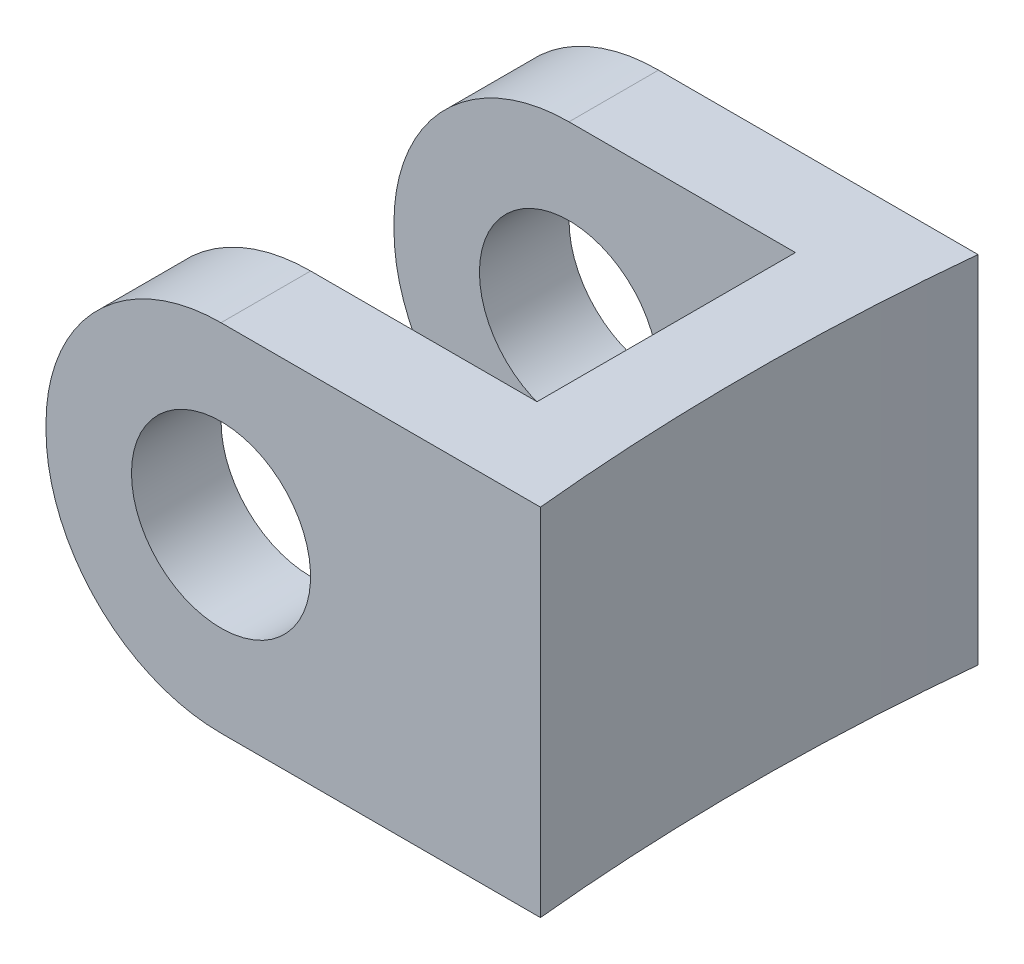
from build123d import *

# Parameters (mm, degrees)
BOSS_EXTRUDE2_DEPTH = 8.255
FILLET1_R           = 4.064
SKETCH2_R           = 2.07899
CUT_EXTRUDE1_DEPTH  = 11.16


with BuildPart() as part:
    # Sketch1 → Boss-Extrude2 (new body)
    with BuildSketch(Plane(origin=(0, 0, 0), x_dir=(1, 0, 0), z_dir=(0, 1, 0))):
        with BuildLine():
            Line((0, 0), (11.2268, 0))
            Line((11.2268, 0), (11.481438195, 0))
            ThreePointArc((11.481438195, 0), (11.2268, -5.08), (11.481438195, -10.16))
            Line((11.481438195, -10.16), (11.2268, -10.16))
            Line((11.2268, -10.16), (0, -10.16))
            Line((0, -10.16), (0, -8.07974))
            Line((0, -8.07974), (9.3218, -8.07974))
            Line((9.3218, -8.07974), (9.3218, -5.08))
            Line((9.3218, -5.08), (9.3218, -2.08026))
            Line((9.3218, -2.08026), (0, -2.08026))
            Line((0, -2.08026), (0, 0))
        make_face()
    extrude(amount=BOSS_EXTRUDE2_DEPTH)

    # Fillet1
    fillet1_edges = [part.edges().sort_by_distance(p)[0] for p in [
        (0, 0, 9.11987),
        (0, 0, 1.04013),
        (0, 8.255, 9.11987),
        (0, 8.255, 1.04013),
    ]]
    fillet(fillet1_edges, radius=FILLET1_R)

    # Sketch2 → Cut-Extrude1 (cut, through all)
    with BuildSketch(Plane(origin=(0, 0, 0), x_dir=(-1, 0, 0), z_dir=(0, 0, -1))):
        with Locations((-4.064, 4.191)):
            Circle(SKETCH2_R)
    extrude(amount=-CUT_EXTRUDE1_DEPTH, mode=Mode.SUBTRACT)


solid = part.part
